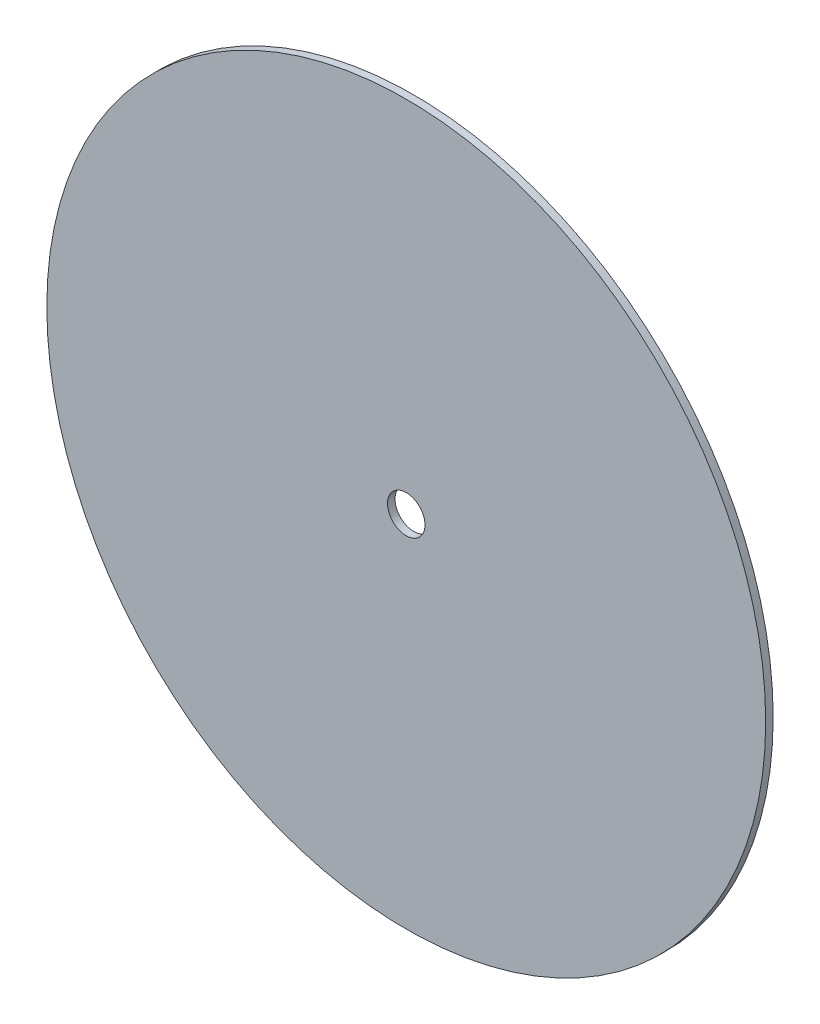
from build123d import *

# Parameters (mm, degrees)
SKETCH1_R           = 152.4
SKETCH1_R_2         = 7.9375
BOSS_EXTRUDE1_DEPTH = 1.5875


with BuildPart() as part:
    # Sketch1 → Boss-Extrude1 (new body, symmetric)
    with BuildSketch(Plane.XY):
        Circle(SKETCH1_R)
        Circle(SKETCH1_R_2, mode=Mode.SUBTRACT)
    extrude(amount=BOSS_EXTRUDE1_DEPTH, both=True)


solid = part.part
